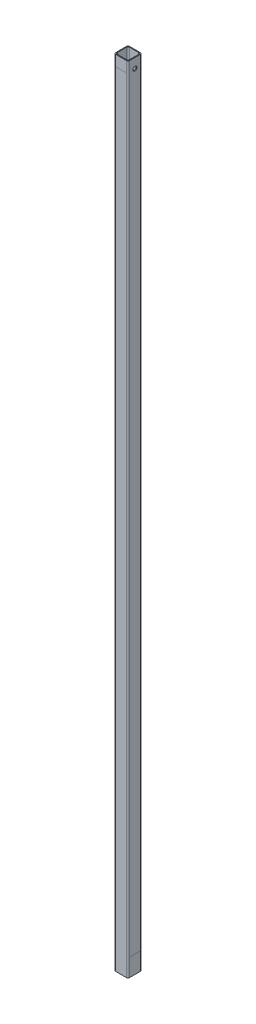
from build123d import *

# Parameters (mm, degrees)
SKETCH1_W               = 22.6822
SKETCH1_H               = 22.6822
SKETCH1_W_2             = 20.1422
SKETCH1_H_2             = 20.1422
BOSS_EXTRUDE1_DEPTH     = 1303.02
FILLET1_R               = 2.54
F_1_4_CLEARANCE_HOLE1_D = 6.7564


with BuildPart() as part:
    # Sketch1 → Boss-Extrude1 (new body)
    with BuildSketch(Plane(origin=(0, 0, 0), x_dir=(1, 0, 0), z_dir=(0, 1, 0))):
        Rectangle(SKETCH1_W, SKETCH1_H)
        Rectangle(SKETCH1_W_2, SKETCH1_H_2, mode=Mode.SUBTRACT)
    extrude(amount=BOSS_EXTRUDE1_DEPTH)

    # Fillet1
    fillet1_edges = [part.edges().sort_by_distance(p)[0] for p in [
        (10.0711, 651.51, 10.0711),
        (10.0711, 651.51, -10.0711),
        (-10.0711, 651.51, -10.0711),
        (-10.0711, 651.51, 10.0711),
        (11.3411, 651.51, 11.3411),
        (-11.3411, 651.51, 11.3411),
        (-11.3411, 651.51, -11.3411),
        (11.3411, 651.51, -11.3411),
    ]]
    fillet(fillet1_edges, radius=FILLET1_R)

    # 1/4 Clearance Hole1 (through all)
    with Locations(Plane(origin=(11.3411, 0, 0), x_dir=(0, 0, -1), z_dir=(1, 0, 0))):
        with Locations((0, 1287.145)):
            Hole(F_1_4_CLEARANCE_HOLE1_D / 2)


solid = part.part
